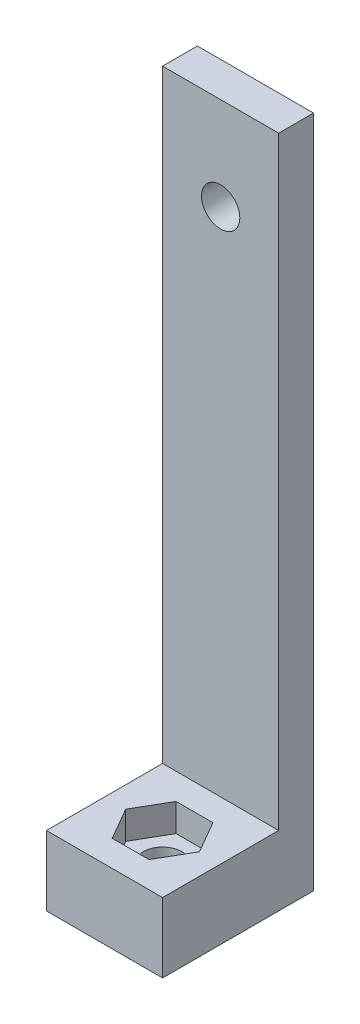
from build123d import *

# Parameters (mm, degrees)
SKETCH1_W           = 10
SKETCH1_H           = 13
SKETCH1_R           = 1.65
BOSS_EXTRUDE1_DEPTH = 6
CUT_EXTRUDE1_DEPTH  = 2.4
SKETCH3_W           = 10
SKETCH3_H           = 58
BOSS_EXTRUDE2_DEPTH = 3
SKETCH4_R           = 1.65
CUT_EXTRUDE2_DEPTH  = 3


with BuildPart() as part:
    # Sketch1 → Boss-Extrude1 (new body)
    with BuildSketch(Plane(origin=(0, 0, 0), x_dir=(1, 0, 0), z_dir=(0, 1, 0))):
        with Locations((0, 1.5)):
            Rectangle(SKETCH1_W, SKETCH1_H)
        Circle(SKETCH1_R, mode=Mode.SUBTRACT)
    extrude(amount=BOSS_EXTRUDE1_DEPTH)

    # Sketch2 → Cut-Extrude1 (cut)
    with BuildSketch(Plane(origin=(0, 6, 0), x_dir=(1, 0, 0), z_dir=(0, 1, 0))):
        Polygon((3.175426481, 0), (1.58771324, 2.75), (-1.58771324, 2.75), (-3.175426481, 0), (-1.58771324, -2.75), (1.58771324, -2.75), align=None)
    extrude(amount=-CUT_EXTRUDE1_DEPTH, mode=Mode.SUBTRACT)

    # Sketch3 → Boss-Extrude2 (add)
    with BuildSketch(Plane(origin=(0, 0, -8), x_dir=(-1, 0, 0), z_dir=(0, 0, -1))):
        with Locations((0, 29)):
            Rectangle(SKETCH3_W, SKETCH3_H)
    extrude(amount=-BOSS_EXTRUDE2_DEPTH)

    # Sketch4 → Cut-Extrude2 (cut)
    with BuildSketch(Plane.XY.offset(-5)):
        with Locations((0, 50)):
            Circle(SKETCH4_R)
    extrude(amount=-CUT_EXTRUDE2_DEPTH, mode=Mode.SUBTRACT)


solid = part.part
